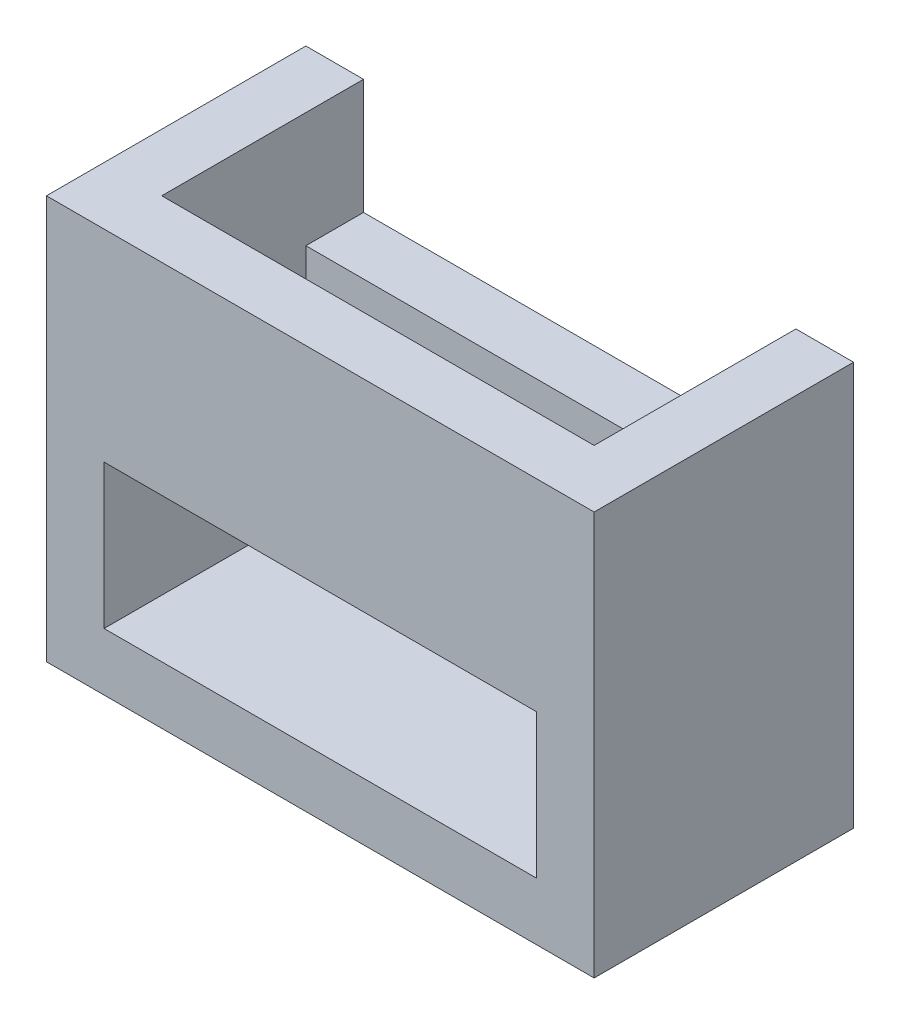
from build123d import *

# Parameters (mm, degrees)
SKETCH2_W           = 19
SKETCH2_H           = 14
BOSS_EXTRUDE1_DEPTH = 9
SKETCH3_W           = 15
SKETCH3_H           = 5
CUT_EXTRUDE1_DEPTH  = 5
SKETCH6_W           = 15
SKETCH6_H           = 7
CUT_EXTRUDE3_DEPTH  = 4
SKETCH7_W           = 15
SKETCH7_H           = 5
CUT_EXTRUDE4_DEPTH  = 4


with BuildPart() as part:
    # Sketch2 → Boss-Extrude1 (new body)
    with BuildSketch(Plane.XY):
        Rectangle(SKETCH2_W, SKETCH2_H)
    extrude(amount=BOSS_EXTRUDE1_DEPTH)

    # Sketch3 → Cut-Extrude1 (cut)
    with BuildSketch(Plane.XY.offset(9)):
        with Locations((0, -2.5)):
            Rectangle(SKETCH3_W, SKETCH3_H)
    extrude(amount=-CUT_EXTRUDE1_DEPTH, mode=Mode.SUBTRACT)

    # Sketch6 → Cut-Extrude3 (cut)
    with BuildSketch(Plane(origin=(0, 7, 0), x_dir=(1, 0, 0), z_dir=(0, 1, 0))):
        with Locations((0, -3.5)):
            Rectangle(SKETCH6_W, SKETCH6_H)
    extrude(amount=-CUT_EXTRUDE3_DEPTH, mode=Mode.SUBTRACT)

    # Sketch7 → Cut-Extrude4 (cut)
    with BuildSketch(Plane(origin=(0, 3, 0), x_dir=(1, 0, 0), z_dir=(0, 1, 0))):
        with Locations((0, -4.5)):
            Rectangle(SKETCH7_W, SKETCH7_H)
    extrude(amount=-CUT_EXTRUDE4_DEPTH, mode=Mode.SUBTRACT)


solid = part.part
